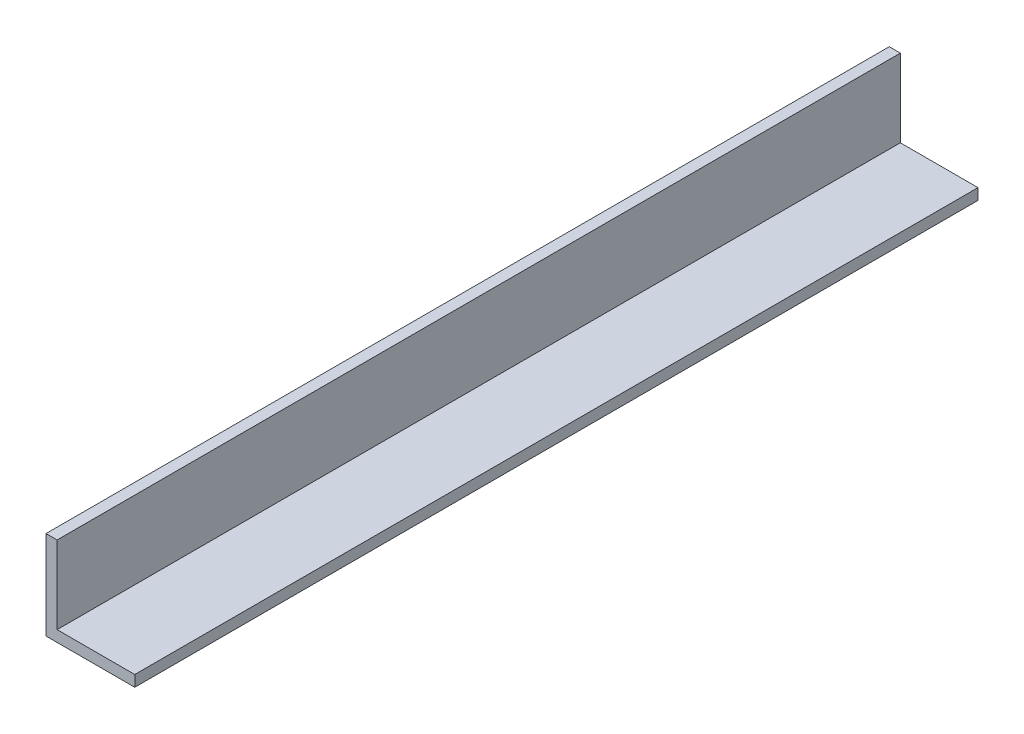
from build123d import *

# Parameters (mm, degrees)
SKETCH1_W           = 3.175
SKETCH1_H           = 22.225
SKETCH1_W_2         = 25.4
SKETCH1_H_2         = 3.175
BOSS_EXTRUDE1_DEPTH = 241.3


with BuildPart() as part:
    # Sketch1 → Boss-Extrude1 (new body)
    with BuildSketch(Plane.XY):
        with Locations((1.5875, 14.2875)):
            Rectangle(SKETCH1_W, SKETCH1_H)
        with Locations((12.7, 1.5875)):
            Rectangle(SKETCH1_W_2, SKETCH1_H_2)
    extrude(amount=BOSS_EXTRUDE1_DEPTH)


solid = part.part
